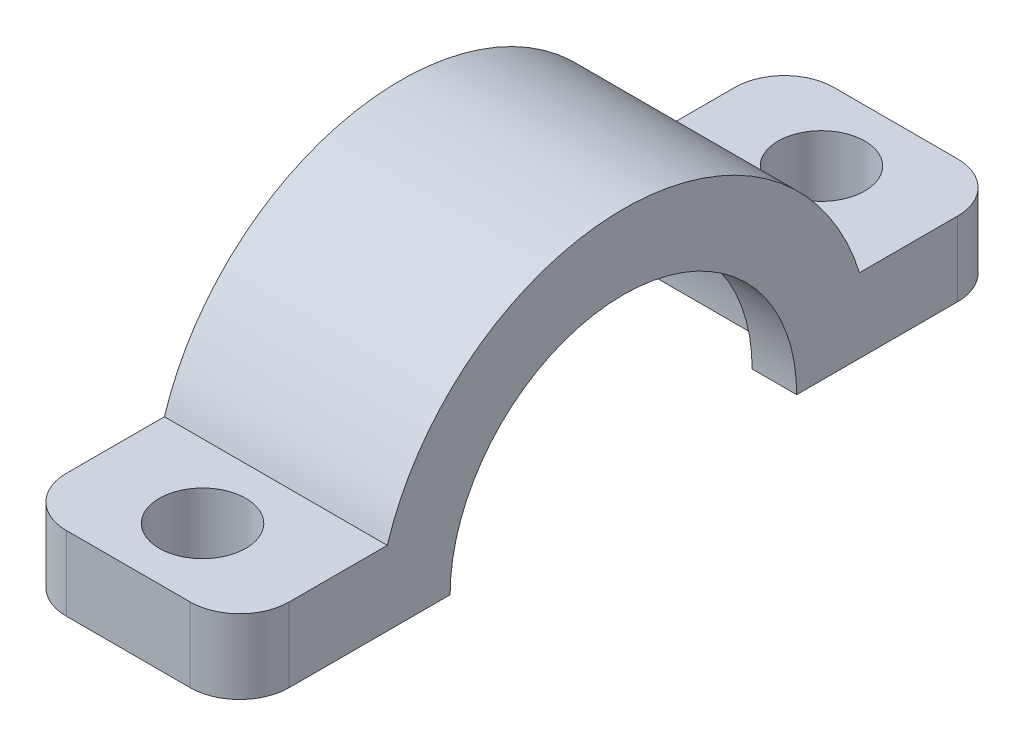
from build123d import *

# Parameters (mm, degrees)
BOSS_EXTRUDE1_DEPTH      = 4.5
BOSS_EXTRUDE1_DEPTH_BACK = 4.5
SKETCH3_R                = 1.75
CUT_EXTRUDE1_DEPTH       = 18.592612086
FILLET1_R                = 2
CUT_EXTRUDE2_DEPTH       = 2.7
CUT_EXTRUDE2_DEPTH_BACK  = 2.7
SKETCH4_R                = 8.25


with BuildPart() as part:
    # Sketch2 → Boss-Extrude1 (new, two sides: drawn at the far end of the back side and taken through both)
    with BuildSketch(Plane(origin=(0, 0, 0), x_dir=(0, 0, -1), z_dir=(1, 0, 0)).offset(-BOSS_EXTRUDE1_DEPTH_BACK)):
        with BuildLine():
            Line((9.539392014, 1.5), (15.5, 1.5))
            Line((15.5, 1.5), (15.5, -1.5))
            Line((15.5, -1.5), (7, -1.5))
            ThreePointArc((7, -1.5), (0, 5.5), (-7, -1.5))
            Line((-7, -1.5), (-15.5, -1.5))
            Line((-15.5, -1.5), (-15.5, 1.5))
            Line((-15.5, 1.5), (-9.539392014, 1.5))
            ThreePointArc((-9.539392014, 1.5), (0, 8.5), (9.539392014, 1.5))
        make_face()
    extrude(amount=BOSS_EXTRUDE1_DEPTH + BOSS_EXTRUDE1_DEPTH_BACK)

    # Sketch3 → Cut-Extrude1 (cut, through all)
    with BuildSketch(Plane(origin=(0, 1.5, 0), x_dir=(1, 0, 0), z_dir=(0, 1, 0))):
        with Locations((0, 12.5)):
            Circle(SKETCH3_R)
        with Locations((0, -12.5)):
            Circle(SKETCH3_R)
    extrude(amount=-CUT_EXTRUDE1_DEPTH, mode=Mode.SUBTRACT)

    # Fillet1
    fillet1_edges = [part.edges().sort_by_distance(p)[0] for p in [
        (4.5, 0, 15.5),
        (-4.5, 0, 15.5),
        (4.5, 0, -15.5),
        (-4.5, 0, -15.5),
    ]]
    fillet(fillet1_edges, radius=FILLET1_R)

    # Sketch4 → Cut-Extrude2 (cut, two sides: drawn at the far end of the back side and taken through both)
    with BuildSketch(Plane(origin=(0, 0, 0), x_dir=(0, 0, -1), z_dir=(1, 0, 0)).offset(-CUT_EXTRUDE2_DEPTH_BACK)):
        with Locations((0, -1.5)):
            Circle(SKETCH4_R)
    extrude(amount=CUT_EXTRUDE2_DEPTH + CUT_EXTRUDE2_DEPTH_BACK, mode=Mode.SUBTRACT)


solid = part.part
